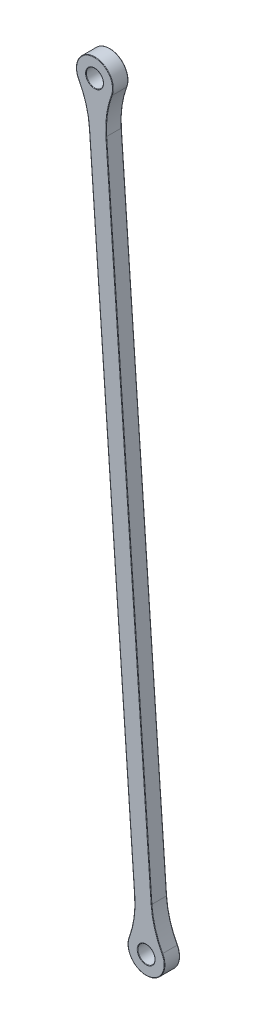
from build123d import *

# Parameters (mm, degrees)
BOSS_EXTRUDE1_DEPTH = 5
FILLET1_R           = 30
FILLET2_R           = 0.15


with BuildPart() as part:
    # Sketch1 → Boss-Extrude1 (new body)
    with BuildSketch(Plane.XY):
        with BuildLine():
            ThreePointArc((22.162679097, 287.964927424), (12.885637759, 292.990959663), (13.742345741, 282.47475562))
            Line((13.742345741, 282.47475562), (13.369595311, 287.768247578))
            ThreePointArc((13.369595311, 287.768247578), (15.965999252, 290.758011211), (18.955762884, 288.16160727))
            Line((18.955762884, 288.16160727), (19.328513314, 282.868115311))
            ThreePointArc((19.328513314, 282.868115311), (21.40648522, 285.049023216), (22.162679097, 287.964927424))
        make_face()
        with BuildLine():
            Line((13.369595311, 287.768247578), (13.742345741, 282.47475562))
            ThreePointArc((13.742345741, 282.47475562), (16.58413591, 281.979747882), (19.328513314, 282.868115311))
            Line((19.328513314, 282.868115311), (18.955762884, 288.16160727))
            ThreePointArc((18.955762884, 288.16160727), (16.359358943, 285.171843638), (13.369595311, 287.768247578))
        make_face()
        with BuildLine():
            ThreePointArc((35.814035392, 48.754425573), (33.217631451, 45.764661941), (30.227867819, 48.361065881))
            Line((30.227867819, 48.361065881), (29.855117389, 53.65455784))
            ThreePointArc((29.855117389, 53.65455784), (30.105047397, 43.313939605), (39.020951605, 48.557745727))
            ThreePointArc((39.020951605, 48.557745727), (38.046983844, 51.834787065), (35.441284962, 54.047917532))
            Line((35.441284962, 54.047917532), (35.814035392, 48.754425573))
        make_face()
        with BuildLine():
            Line((29.855117389, 53.65455784), (30.227867819, 48.361065881))
            ThreePointArc((30.227867819, 48.361065881), (32.824271759, 51.350829514), (35.814035392, 48.754425573))
            Line((35.814035392, 48.754425573), (35.441284962, 54.047917532))
            ThreePointArc((35.441284962, 54.047917532), (32.599494793, 54.54292527), (29.855117389, 53.65455784))
        make_face()
        with BuildLine():
            Line((13.742345741, 282.47475562), (29.855117389, 53.65455784))
            ThreePointArc((29.855117389, 53.65455784), (32.599494793, 54.54292527), (35.441284962, 54.047917532))
            Line((35.441284962, 54.047917532), (19.328513314, 282.868115311))
            ThreePointArc((19.328513314, 282.868115311), (16.58413591, 281.979747882), (13.742345741, 282.47475562))
        make_face()
    extrude(amount=-BOSS_EXTRUDE1_DEPTH)

    # Fillet1
    fillet1_edges = [part.edges().sort_by_distance(p)[0] for p in [
        (29.855117389, 53.65455784, -2.5),
        (13.742345741, 282.47475562, -2.5),
        (19.328513314, 282.868115311, -2.5),
        (35.441284962, 54.047917532, -2.5),
    ]]
    fillet(fillet1_edges, radius=FILLET1_R)

    # Fillet2
    fillet2_edges = [part.edges().sort_by_distance(p)[0] for p in [
        (27.384899138, 168.458016422, 0),
        (27.384899138, 168.458016422, -5),
        (15.741222285, 293.950106967, 0),
        (15.741222285, 293.950106967, -5),
        (18.955762884, 288.16160727, -5),
        (21.798731565, 168.06465673, 0),
        (21.798731565, 168.06465673, -5),
        (31.962941543, 42.651764462, 0),
        (31.962941543, 42.651764462, -5),
        (20.226334284, 279.716762081, 0),
        (20.226334284, 279.716762081, -5),
        (13.295010771, 279.228680898, 0),
        (35.814035392, 48.754425573, -5),
        (13.295010771, 279.228680898, -5),
        (28.957296418, 56.80591107, 0),
        (28.957296418, 56.80591107, -5),
        (35.888619932, 57.293992254, 0),
        (35.888619932, 57.293992254, -5),
        (35.814035392, 48.754425573, 0),
        (18.955762884, 288.16160727, 0),
    ]]
    fillet(fillet2_edges, radius=FILLET2_R)


solid = part.part
